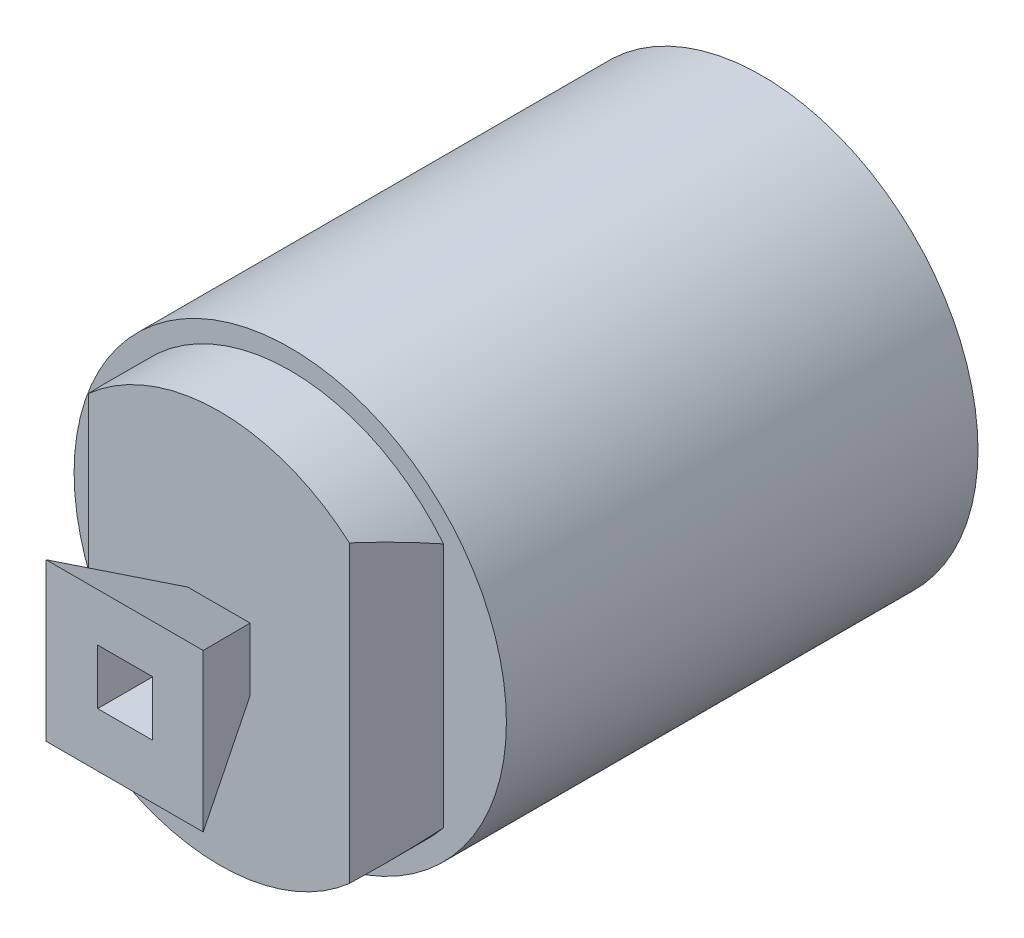
from build123d import *

# Parameters (mm, degrees)
ESBO_O2_R                      = 27.5
RESSALTO_EXTRUS_O1_DEPTH       = 60
CORTE_EXTRUS_O3_DEPTH          = 59
CORTE_EXTRUS_O3_DEPTH_BACK     = 2
ESBO_O3_R                      = 27
ESBO_O4_R                      = 25
RESSALTO_EXTRUS_O10_DEPTH      = 69
CORTE_EXTRUS_O4_DEPTH          = 43
CORTE_EXTRUS_O4_DEPTH_BACK     = 48
RESSALTO_EXTRUS_O11_DEPTH      = 20
RESSALTO_EXTRUS_O11_DEPTH_BACK = 20
CORTE_EXTRUS_O5_DEPTH          = 30
CORTE_EXTRUS_O5_DEPTH_BACK     = 24
ESBO_O10_R                     = 25.877915993
CORTE_EXTRUS_O6_DEPTH          = 59
CORTE_EXTRUS_O7_DEPTH          = 68
CORTE_EXTRUS_O7_DEPTH_BACK     = 1
ESBO_O11_W                     = 32
ESBO_O11_H                     = 36
CORTE_EXTRUS_O10_DEPTH         = 15
CORTE_EXTRUS_O10_DEPTH_BACK    = 15
ESBO_O13_W                     = 7
ESBO_O13_H                     = 7
CORTE_EXTRUS_O11_DEPTH         = 83


with BuildPart() as part:
    # Esboço2 → Ressalto-extrusão1 (new body)
    with BuildSketch(Plane.XY):
        Circle(ESBO_O2_R)
    extrude(amount=RESSALTO_EXTRUS_O1_DEPTH)

    # Esboço3 → Corte-extrusão3 (cut, two sides: drawn at the far end of the back side and taken through both)
    with BuildSketch(Plane.XY.offset(-CORTE_EXTRUS_O3_DEPTH_BACK)):
        Circle(ESBO_O3_R)
    extrude(amount=CORTE_EXTRUS_O3_DEPTH + CORTE_EXTRUS_O3_DEPTH_BACK, mode=Mode.SUBTRACT)

    # Esboço4 → Ressalto-extrusão10 (add)
    with BuildSketch(Plane.XY):
        Circle(ESBO_O4_R)
    extrude(amount=RESSALTO_EXTRUS_O10_DEPTH)

    # Esboço6 → Corte-extrusão4 (cut, two sides: drawn at the far end of the back side and taken through both)
    with BuildSketch(Plane(origin=(0, 0, 0), x_dir=(1, 0, 0), z_dir=(0, 1, 0)).offset(-CORTE_EXTRUS_O4_DEPTH_BACK)):
        Polygon((-27.667910376, -60), (-19.667910376, -60), (-16.667910376, -69), (-27.667910376, -69), align=None)
        Polygon((27.5, -60), (19.5, -60), (16.515708897, -69), (27.5, -69), align=None)
    extrude(amount=CORTE_EXTRUS_O4_DEPTH + CORTE_EXTRUS_O4_DEPTH_BACK, mode=Mode.SUBTRACT)

    # Esboço7 → Ressalto-extrusão11 (add, two sides: drawn at the far end of the back side and taken through both)
    with BuildSketch(Plane(origin=(0, 0, 0), x_dir=(1, 0, 0), z_dir=(0, 1, 0)).offset(-RESSALTO_EXTRUS_O11_DEPTH_BACK)):
        Polygon((-4.043441925, -69), (3.891240446, -69), (9.923899261, -81), (-10.076100739, -81), align=None)
    extrude(amount=RESSALTO_EXTRUS_O11_DEPTH + RESSALTO_EXTRUS_O11_DEPTH_BACK)

    # Esboço9 → Corte-extrusão5 (cut, two sides: drawn at the far end of the back side and taken through both)
    with BuildSketch(Plane(origin=(0, 0, 0), x_dir=(0, 0, -1), z_dir=(1, 0, 0)).offset(-CORTE_EXTRUS_O5_DEPTH_BACK)):
        Polygon((-81, -10.386236586), (-69, -4.386236586), (-69, -22.806779524), (-81, -22.806779524), align=None)
        Polygon((-69, 3.613763414), (-81, 9.613763414), (-81, 21.387044081), (-69, 21.387044081), align=None)
    extrude(amount=CORTE_EXTRUS_O5_DEPTH + CORTE_EXTRUS_O5_DEPTH_BACK, mode=Mode.SUBTRACT)

    # Esboço10 → Corte-extrusão6 (cut)
    with BuildSketch(Plane.XY):
        Circle(ESBO_O10_R)
    extrude(amount=CORTE_EXTRUS_O6_DEPTH, mode=Mode.SUBTRACT)

    # Esboço11 → Corte-extrusão7 (cut, two sides: drawn at the far end of the back side and taken through both)
    with BuildSketch(Plane.XY.offset(-CORTE_EXTRUS_O7_DEPTH_BACK)):
        Rectangle(ESBO_O11_W, ESBO_O11_H)
    extrude(amount=CORTE_EXTRUS_O7_DEPTH + CORTE_EXTRUS_O7_DEPTH_BACK, mode=Mode.SUBTRACT)

    # Esboço12 → Corte-extrusão10 (cut, two sides: drawn at the far end of the back side and taken through both)
    with BuildSketch(Plane(origin=(0, 0, 0), x_dir=(1, 0, 0), z_dir=(0, 1, 0)).offset(-CORTE_EXTRUS_O10_DEPTH_BACK)):
        Polygon((-19.069725689, -58.817820976), (18.89199626, -58.817820976), (15.847296797, -68), (-15.94876003, -68), align=None)
    extrude(amount=CORTE_EXTRUS_O10_DEPTH + CORTE_EXTRUS_O10_DEPTH_BACK, mode=Mode.SUBTRACT)

    # Esboço13 → Corte-extrusão11 (cut)
    with BuildSketch(Plane.XY):
        Rectangle(ESBO_O13_W, ESBO_O13_H)
    extrude(amount=CORTE_EXTRUS_O11_DEPTH, mode=Mode.SUBTRACT)


solid = part.part
